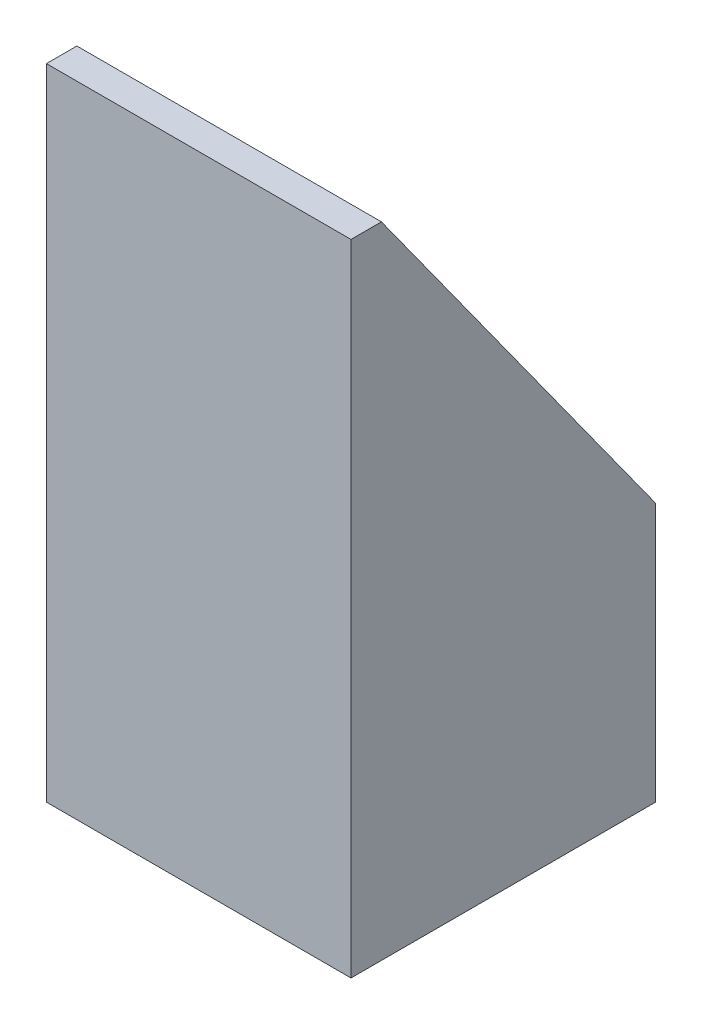
from build123d import *

# Parameters (mm, degrees)
SZKIC1_W                        = 20
SZKIC1_H                        = 20
SZKIC1_W_2                      = 16
SZKIC1_H_2                      = 16
DODANIE_WYCI_GNI_CIE1_DEPTH     = 40
WYTNIJ_WYCI_GNI_CIE1_DEPTH      = 1
WYTNIJ_WYCI_GNI_CIE1_DEPTH_BACK = 21
SZKIC3_W                        = 20
SZKIC3_H                        = 20
DODANIE_WYCI_GNI_CIE2_DEPTH     = 2
SZKIC4_R                        = 2
WYTNIJ_WYCI_GNI_CIE2_DEPTH      = 2


with BuildPart() as part:
    # Szkic1 → Dodanie-wyciągnięcie1 (new body)
    with BuildSketch(Plane(origin=(0, 0, 0), x_dir=(1, 0, 0), z_dir=(0, 1, 0))):
        with Locations((10, -10)):
            Rectangle(SZKIC1_W, SZKIC1_H)
        with Locations((10, -10)):
            Rectangle(SZKIC1_W_2, SZKIC1_H_2, mode=Mode.SUBTRACT)
    extrude(amount=DODANIE_WYCI_GNI_CIE1_DEPTH)

    # Szkic2 → Wytnij-wyciągnięcie1 (cut, two sides)
    with BuildSketch(Plane(origin=(20, 0, 0), x_dir=(0, 0, -1), z_dir=(1, 0, 0))) as wytnij_wyci_gni_cie1_sk:
        Polygon((-18, 40), (0, 15), (0, 40), align=None)
    extrude(amount=WYTNIJ_WYCI_GNI_CIE1_DEPTH, mode=Mode.SUBTRACT)
    extrude(wytnij_wyci_gni_cie1_sk.sketch, amount=-WYTNIJ_WYCI_GNI_CIE1_DEPTH_BACK, mode=Mode.SUBTRACT)

    # Szkic3 → Dodanie-wyciągnięcie2 (add)
    with BuildSketch(Plane.XZ):
        with Locations((10, 10)):
            Rectangle(SZKIC3_W, SZKIC3_H)
    extrude(amount=DODANIE_WYCI_GNI_CIE2_DEPTH)

    # Szkic4 → Wytnij-wyciągnięcie2 (cut)
    with BuildSketch(Plane.XZ.offset(2)):
        with Locations((10, 14)):
            Circle(SZKIC4_R)
        with Locations((10, 6)):
            Circle(SZKIC4_R)
    extrude(amount=-WYTNIJ_WYCI_GNI_CIE2_DEPTH, mode=Mode.SUBTRACT)


solid = part.part
